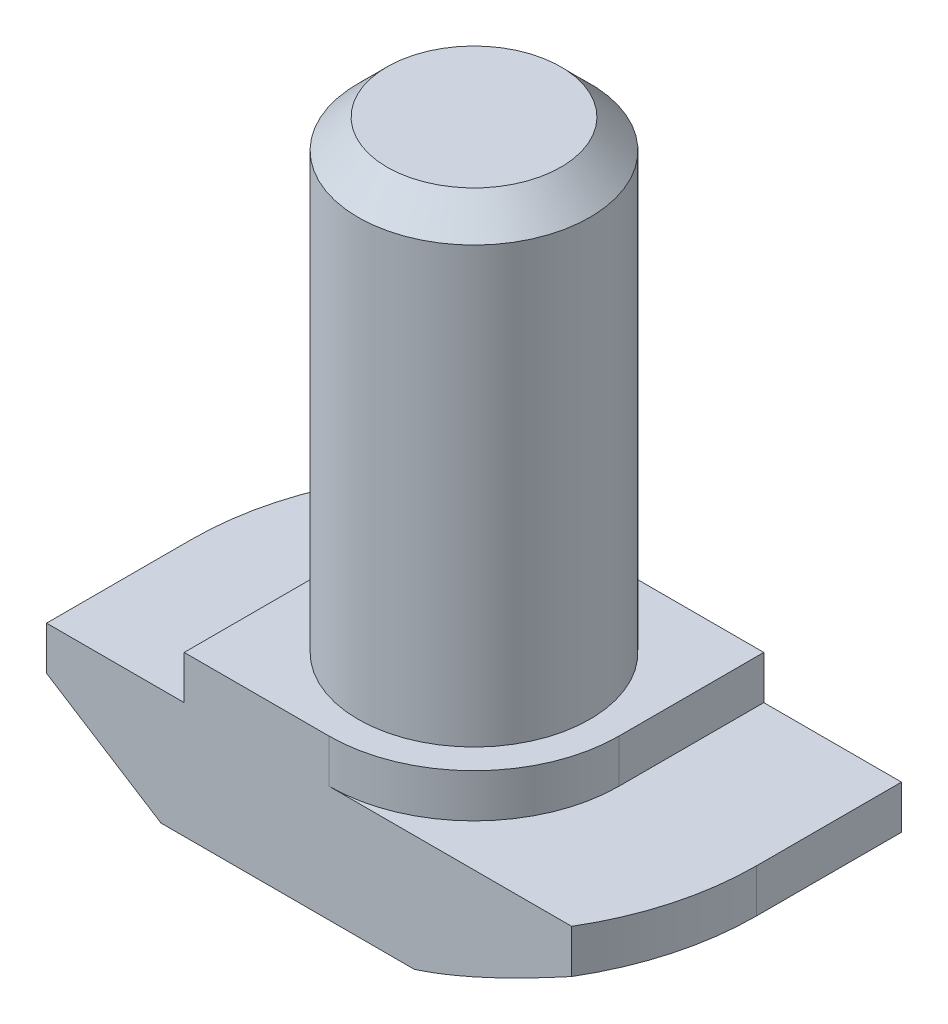
from build123d import *

# Parameters (mm, degrees)
EXTRUDE_1_DEPTH     = 5
CUT_EXTRUDE_1_DEPTH = 1.5
SKETCH_2_R          = 4
EXTRUDE_2_DEPTH     = 16
CUT_EXTRUDE_2_DEPTH = 5
CHAMFER_2_SIZE      = 1


with BuildPart() as part:
    # Эскиз1 → Бобышка-Вытянуть1 (new body, symmetric)
    with BuildSketch(Plane.XY):
        Polygon((9.75, 0), (-9.75, 0), (-9.75, 4), (-5, 4), (-5, 5.5), (5, 5.5), (5, 4), (9.75, 4), align=None)
    extrude(amount=EXTRUDE_1_DEPTH, both=True)

    # Эскиз3 → Вырез-Вытянуть1 (cut)
    with BuildSketch(Plane(origin=(0, 5.5, 0), x_dir=(1, 0, 0), z_dir=(0, 1, 0))):
        with BuildLine():
            Line((-5, 0), (-5, 5))
            Line((-5, 5), (0, 5))
            ThreePointArc((0, 5), (-3.535533906, 3.535533906), (-5, 0))
        make_face()
        with BuildLine():
            Line((0, -5), (5, -5))
            Line((5, -5), (5, 0))
            ThreePointArc((5, 0), (3.535533906, -3.535533906), (0, -5))
        make_face()
    extrude(amount=-CUT_EXTRUDE_1_DEPTH, mode=Mode.SUBTRACT)

    # Эскиз2 → Бобышка-Вытянуть2 (add)
    with BuildSketch(Plane(origin=(0, 5.5, 0), x_dir=(1, 0, 0), z_dir=(0, 1, 0))):
        with Locations(Location((0, 0, 0), (0, 0, 270))):  # turned: the seam where the file's is
            Circle(SKETCH_2_R)
    extrude(amount=EXTRUDE_2_DEPTH)

    # Эскиз4 → Вырез-Вытянуть2 (cut, through all)
    with BuildSketch(Plane(origin=(0, 4, 0), x_dir=(1, 0, 0), z_dir=(0, 1, 0))):
        with BuildLine():
            Line((-8.370334521, 5), (-9.75, 5))
            Line((-9.75, 5), (-9.75, 0))
            ThreePointArc((-9.75, 0), (-9.398756875, 2.59342808), (-8.370334521, 5))
        make_face()
        with BuildLine():
            Line((8.370334521, -5), (9.75, -5))
            Line((9.75, -5), (9.75, 0))
            ThreePointArc((9.75, 0), (9.398756875, -2.59342808), (8.370334521, -5))
        make_face()
    extrude(amount=-CUT_EXTRUDE_2_DEPTH, mode=Mode.SUBTRACT)

    # Вырез-По траектории1: sweep along a path in Эскиз6
    with BuildLine(Plane.XZ) as sweep_1_path:
        Line((0, -9.75), (9.75, -9.75))
        Line((9.75, -9.75), (9.75, 0))
        ThreePointArc((9.75, 0), (6.894291117, 6.894291117), (0, 9.75))
        Line((0, 9.75), (-9.75, 9.75))
        Line((-9.75, 9.75), (-9.75, 0))
        ThreePointArc((-9.75, 0), (-6.894291117, -6.894291117), (0, -9.75))
    # Эскиз5 → Вырез-По траектории1 (sweep, cut)
    with BuildSketch(Plane.XY.offset(5)):
        Polygon((-9.75, 2.5), (-5.8, 0), (-9.75, 0), align=None)
    sweep(path=sweep_1_path.line, transition=Transition.RIGHT, mode=Mode.SUBTRACT)

    # Фаска2
    chamfer_2_edges = [part.edges().sort_by_distance(p)[0] for p in [
        (0, 21.5, -4),
    ]]
    chamfer(chamfer_2_edges, length=CHAMFER_2_SIZE)


solid = part.part
